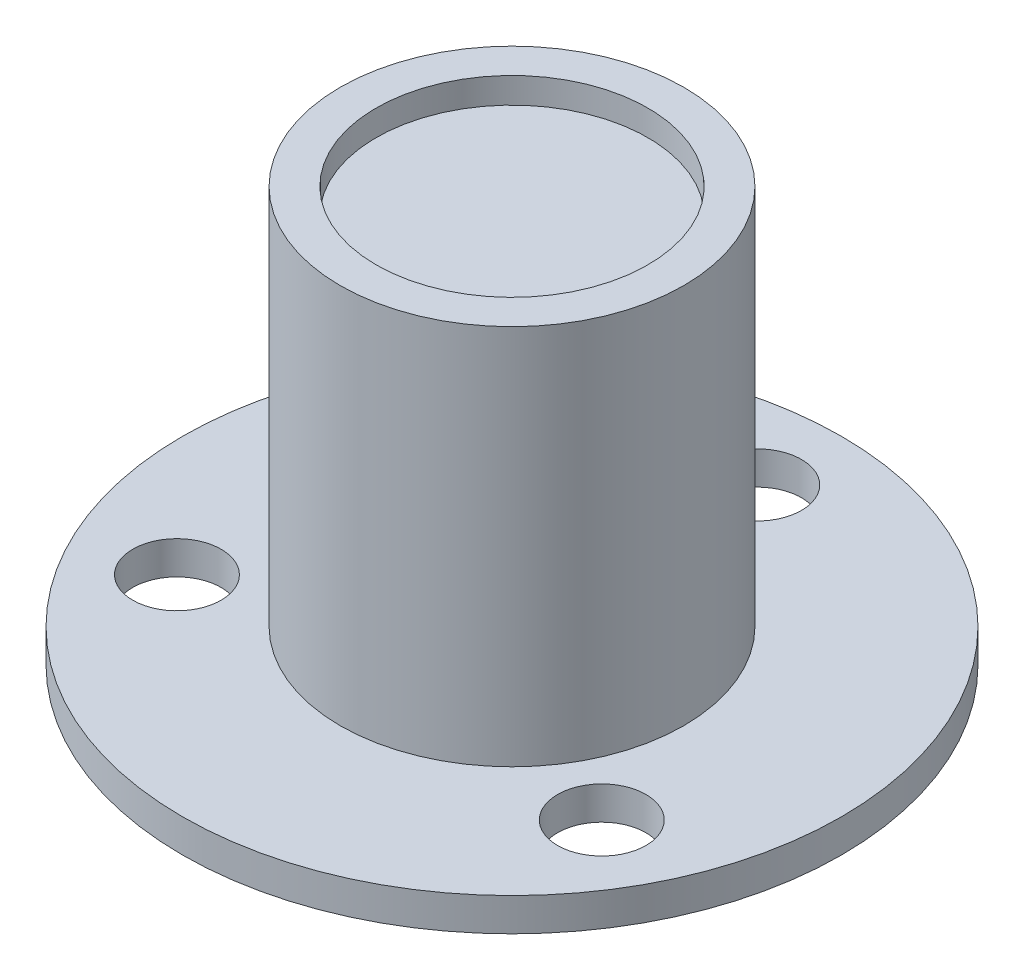
from build123d import *

# Parameters (mm, degrees)
SKETCH1_R           = 6.22
BOSS_EXTRUDE1_DEPTH = 15
SKETCH2_R           = 11.93
BOSS_EXTRUDE2_DEPTH = 1.2
CUT_EXTRUDE1_REACH  = 3.2
SKETCH3_R           = 1.6
SKETCH4_R           = 4.92
CUT_EXTRUDE2_DEPTH  = 0.93
SKETCH5_R           = 4.875
BOSS_EXTRUDE3_DEPTH = 0.76
SKETCH6_R           = 2.425
BOSS_EXTRUDE4_DEPTH = 1.88
SKETCH7_R           = 5.445
SKETCH7_R_2         = 4.875
CUT_EXTRUDE3_DEPTH  = 0.25


with BuildPart() as part:
    # Sketch1 → Boss-Extrude1 (new body)
    with BuildSketch(Plane(origin=(0, 0, 0), x_dir=(1, 0, 0), z_dir=(0, 1, 0))):
        Circle(SKETCH1_R)
    extrude(amount=BOSS_EXTRUDE1_DEPTH)

    # Sketch2 → Boss-Extrude2 (add)
    with BuildSketch(Plane.XZ):
        Circle(SKETCH2_R)
    extrude(amount=-BOSS_EXTRUDE2_DEPTH)

    # Sketch3 → Cut-Extrude1 (cut, up to next)
    with BuildSketch(Plane(origin=(0, 1.2, 0), x_dir=(1, 0, 0), z_dir=(0, 1, 0)), mode=Mode.PRIVATE) as cut_extrude1_sk1:
        with Locations((0, 8.88)):
            Circle(SKETCH3_R)
    cut_extrude1_tool1 = extrude(cut_extrude1_sk1.sketch, amount=-CUT_EXTRUDE1_REACH, mode=Mode.PRIVATE) & part.part
    add(cut_extrude1_tool1.solids().sort_by_distance((0, 1.2, -8.88))[0], mode=Mode.SUBTRACT)
    # Sketch3 → Cut-Extrude1 (cut, up to next)
    with BuildSketch(Plane(origin=(0, 1.2, 0), x_dir=(1, 0, 0), z_dir=(0, 1, 0)), mode=Mode.PRIVATE) as cut_extrude1_sk2:
        with Locations((7.690305586, -4.44)):
            Circle(SKETCH3_R)
    cut_extrude1_tool2 = extrude(cut_extrude1_sk2.sketch, amount=-CUT_EXTRUDE1_REACH, mode=Mode.PRIVATE) & part.part
    add(cut_extrude1_tool2.solids().sort_by_distance((7.690306, 1.2, 4.44))[0], mode=Mode.SUBTRACT)
    # Sketch3 → Cut-Extrude1 (cut, up to next)
    with BuildSketch(Plane(origin=(0, 1.2, 0), x_dir=(1, 0, 0), z_dir=(0, 1, 0)), mode=Mode.PRIVATE) as cut_extrude1_sk3:
        with Locations((-7.690305586, -4.44)):
            Circle(SKETCH3_R)
    cut_extrude1_tool3 = extrude(cut_extrude1_sk3.sketch, amount=-CUT_EXTRUDE1_REACH, mode=Mode.PRIVATE) & part.part
    add(cut_extrude1_tool3.solids().sort_by_distance((-7.690306, 1.2, 4.44))[0], mode=Mode.SUBTRACT)

    # Sketch4 → Cut-Extrude2 (cut)
    with BuildSketch(Plane(origin=(0, 15, 0), x_dir=(1, 0, 0), z_dir=(0, 1, 0))):
        Circle(SKETCH4_R)
    extrude(amount=-CUT_EXTRUDE2_DEPTH, mode=Mode.SUBTRACT)

    # Sketch5 → Boss-Extrude3 (add)
    with BuildSketch(Plane.XZ):
        Circle(SKETCH5_R)
    extrude(amount=BOSS_EXTRUDE3_DEPTH)

    # Sketch6 → Boss-Extrude4 (add)
    with BuildSketch(Plane.XZ.offset(0.76)):
        Circle(SKETCH6_R)
    extrude(amount=BOSS_EXTRUDE4_DEPTH)

    # Sketch7 → Cut-Extrude3 (cut)
    with BuildSketch(Plane.XZ):
        Circle(SKETCH7_R)
        Circle(SKETCH7_R_2, mode=Mode.SUBTRACT)
    extrude(amount=-CUT_EXTRUDE3_DEPTH, mode=Mode.SUBTRACT)


solid = part.part
